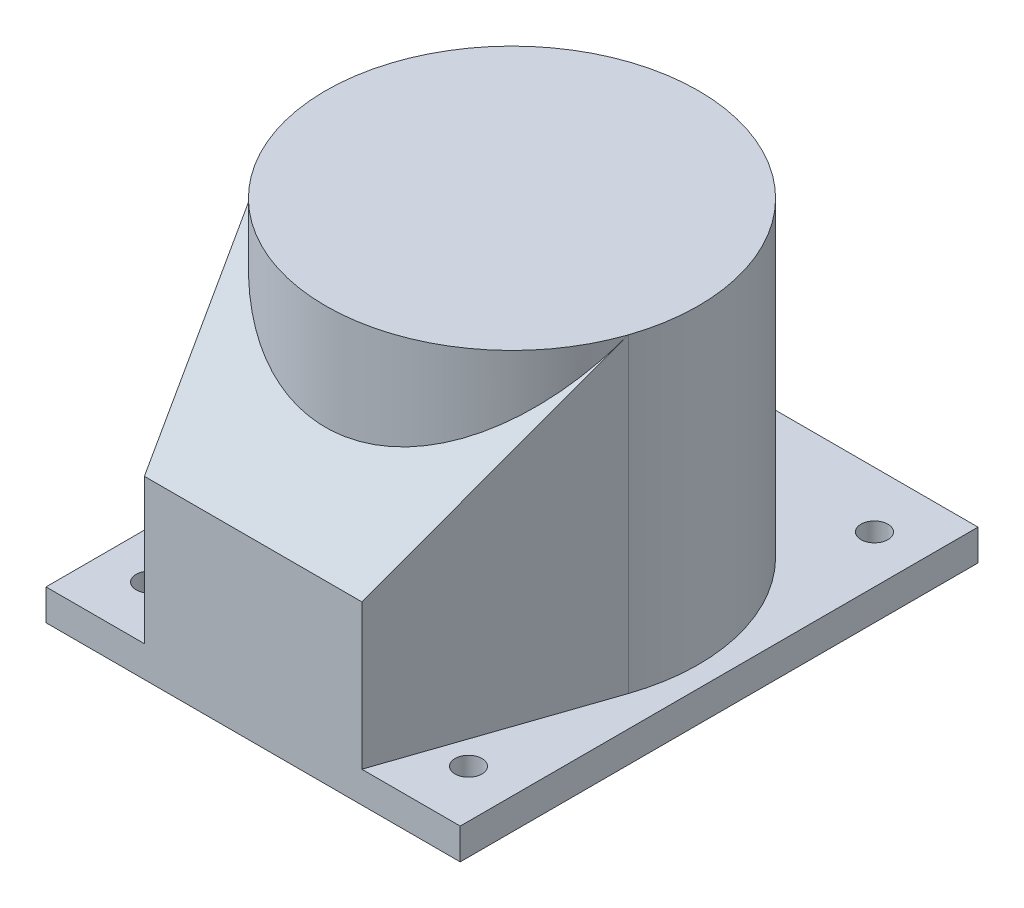
from build123d import *

# Parameters (mm, degrees)
SKETCH1_W               = 250
SKETCH1_H               = 200
SKETCH1_R               = 6.5
BOSS_EXTRUDE1_DEPTH     = 15
BOSS_EXTRUDE2_DEPTH     = 150
CUT_EXTRUDE1_DEPTH      = 101
CUT_EXTRUDE1_DEPTH_BACK = 101
BOSS_EXTRUDE3_REACH     = 167
BODY_MOVE_COPY1_ANGLE   = 90


with BuildPart() as part:
    # Sketch1 → Boss-Extrude1 (new body)
    with BuildSketch(Plane(origin=(0, 0, 0), x_dir=(1, 0, 0), z_dir=(0, 1, 0))):
        Rectangle(SKETCH1_W, SKETCH1_H)
        with Locations((-98, 77)):
            Circle(SKETCH1_R, mode=Mode.SUBTRACT)
        with Locations((98, 77)):
            Circle(SKETCH1_R, mode=Mode.SUBTRACT)
        with Locations((-98, -77)):
            Circle(SKETCH1_R, mode=Mode.SUBTRACT)
        with Locations((98, -77)):
            Circle(SKETCH1_R, mode=Mode.SUBTRACT)
    extrude(amount=BOSS_EXTRUDE1_DEPTH)

    # Sketch2 → Boss-Extrude2 (add)
    with BuildSketch(Plane(origin=(0, 15, 0), x_dir=(1, 0, 0), z_dir=(0, 1, 0))):
        with BuildLine():
            Line((125, 52.5), (29.018785036, 85.193368962))
            ThreePointArc((29.018785036, 85.193368962), (-90, 0), (29.018785036, -85.193368962))
            Line((29.018785036, -85.193368962), (125, -52.5))
            Line((125, -52.5), (125, 52.5))
        make_face()
    extrude(amount=BOSS_EXTRUDE2_DEPTH)

    # Sketch3 → Cut-Extrude1 (cut, two sides)
    with BuildSketch(Plane.XY) as cut_extrude1_sk:
        Polygon((-384.335484925, 509.529308254), (29.018785036, 165), (125, 85), (538.354269961, -259.529308254), (1227.412886469, 567.179231668), (304.723131583, 1336.237848176), align=None)
    extrude(amount=CUT_EXTRUDE1_DEPTH, mode=Mode.SUBTRACT)
    extrude(cut_extrude1_sk.sketch, amount=-CUT_EXTRUDE1_DEPTH_BACK, mode=Mode.SUBTRACT)

    # Sketch4 → Boss-Extrude3 (add, up to next)
    with BuildSketch(Plane(origin=(0, 165, 0), x_dir=(1, 0, 0), z_dir=(0, 1, 0)), mode=Mode.PRIVATE) as boss_extrude3_sk1:
        with BuildLine():
            Line((29.018785036, -85.193368962), (29.018785036, 85.193368962))
            ThreePointArc((29.018785036, 85.193368962), (90, 0), (29.018785036, -85.193368962))
        make_face()
    boss_extrude3_tool1 = extrude(boss_extrude3_sk1.sketch, amount=-BOSS_EXTRUDE3_REACH, mode=Mode.PRIVATE) - part.part
    add(boss_extrude3_tool1.solids().sort_by_distance((54.295969, 165, 0))[0])


with BuildPart() as part_1:
    # Body-Move/Copy1: moved
    add(part.part.rotate(Axis((0, 0, 0), (0, -1, 0)), BODY_MOVE_COPY1_ANGLE))


solid = part_1.part
